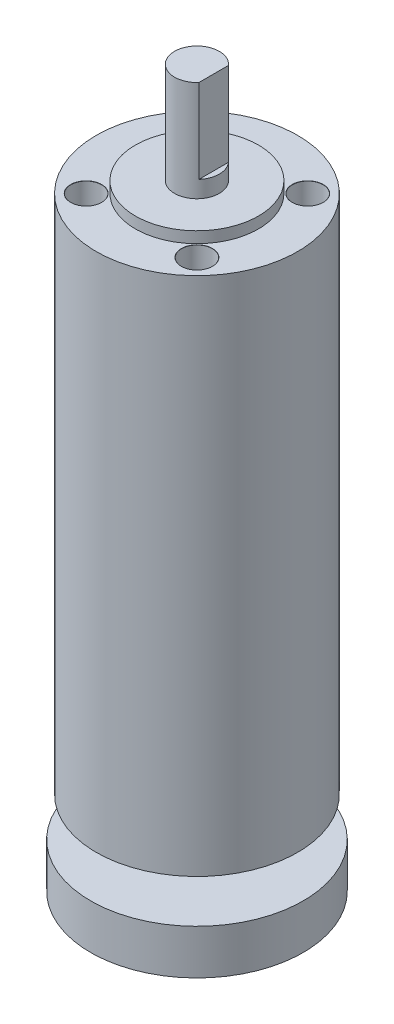
from build123d import *

# Parameters (mm, degrees)
SKETCH2_W                      = 1.704522774
SKETCH2_H                      = 15
CUT_EXTRUDE1_DEPTH             = 20
CUT_EXTRUDE1_DEPTH_BACK        = 20
M5_CLEARANCE_HOLE1_D           = 5.5
M5_CLEARANCE_HOLE1_DEPTH       = 13
M5_CLEARANCE_HOLE1_CSINK_D     = 5.55
M5_CLEARANCE_HOLE1_CSINK_ANGLE = 90
M5_CLEARANCE_HOLE1_TIP         = 1.652366702


with BuildPart() as part:
    # Sketch1 → Revolve1 (revolve)
    with BuildSketch(Plane.XY):
        Polygon((18, 93), (11, 93), (11, 95), (4, 95), (4, 113), (0, 113), (0, 0), (0, -15), (19, -15), (19, -7), (7, -7), (7, 0), (18, 0), (18, 57), align=None)
    revolve(axis=Axis((0, 113, 0), (0, -1, 0)))

    # Sketch2 → Cut-Extrude1 (cut, two sides)
    with BuildSketch(Plane.XY) as cut_extrude1_sk:
        with Locations((3.852261387, 105.5)):
            Rectangle(SKETCH2_W, SKETCH2_H)
    extrude(amount=CUT_EXTRUDE1_DEPTH, mode=Mode.SUBTRACT)
    extrude(cut_extrude1_sk.sketch, amount=-CUT_EXTRUDE1_DEPTH_BACK, mode=Mode.SUBTRACT)

    # M5 Clearance Hole1
    with Locations(Plane(origin=(0, 93, 0), x_dir=(1, 0, 0), z_dir=(0, 1, 0))):
        with Locations((-9.899494937, 9.899494937), (-9.899494937, -9.899494937), (9.899494937, -9.899494937), (9.899494937, 9.899494937)):
            CounterSinkHole(M5_CLEARANCE_HOLE1_D / 2, M5_CLEARANCE_HOLE1_CSINK_D / 2, depth=M5_CLEARANCE_HOLE1_DEPTH, counter_sink_angle=M5_CLEARANCE_HOLE1_CSINK_ANGLE)
            with Locations((0, 0, -(M5_CLEARANCE_HOLE1_DEPTH + M5_CLEARANCE_HOLE1_TIP / 2))):  # 118° drill point
                Cone(0, M5_CLEARANCE_HOLE1_D / 2, M5_CLEARANCE_HOLE1_TIP, mode=Mode.SUBTRACT)


solid = part.part
